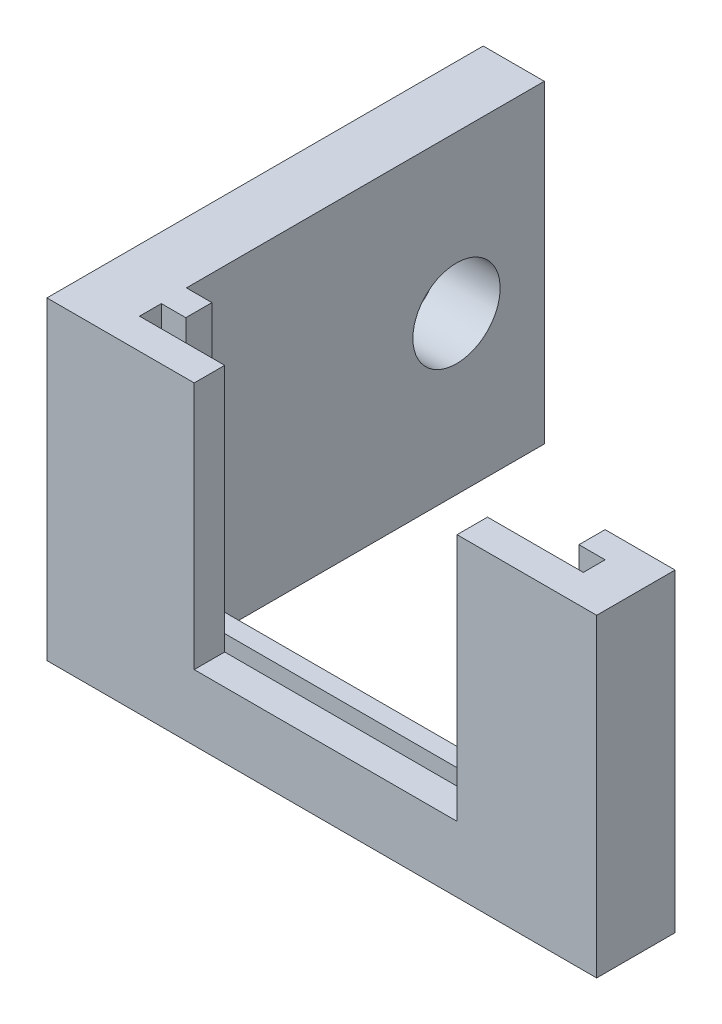
from build123d import *

# Parameters (mm, degrees)
SKETCH_2_W               = 3.5
SKETCH_2_H               = 18
EXTRUDE_1_DEPTH          = 25
SKETCH_3_W               = 4.492765479
SKETCH_3_H               = 18
EXTRUDE_2_DEPTH          = 28
CUT_EXTRUDE_1_DEPTH      = 15
SKETCH_5_W               = 18
SKETCH_5_H               = 1.12
CUT_EXTRUDE_2_DEPTH      = 4
SKETCH_6_W               = 15.061219586
SKETCH_6_H               = 9.659551438
CUT_EXTRUDE_3_DEPTH      = 26
SKETCH_7_R               = 2.5
CUT_EXTRUDE_4_DEPTH      = 1
CUT_EXTRUDE_4_DEPTH_BACK = 32.5
SKETCH_8_W               = 15.061219586
SKETCH_8_H               = 1.746167636
CUT_EXTRUDE_5_DEPTH      = 5.566914265


with BuildPart() as part:
    # Эскиз2 → Бобышка-Вытянуть1 (new body)
    with BuildSketch(Plane.XY):
        with Locations((1.75, 9)):
            Rectangle(SKETCH_2_W, SKETCH_2_H)
    extrude(amount=EXTRUDE_1_DEPTH)

    # Эскиз3 → Бобышка-Вытянуть2 (add)
    with BuildSketch(Plane(origin=(3.5, 0, 0), x_dir=(0, 0, -1), z_dir=(1, 0, 0))):
        with Locations((-22.753617261, 9)):
            Rectangle(SKETCH_3_W, SKETCH_3_H)
    extrude(amount=EXTRUDE_2_DEPTH)

    # Эскиз4 → Вырез-Вытянуть1 (cut)
    with BuildSketch(Plane(origin=(0, 18, 0), x_dir=(1, 0, 0), z_dir=(0, 1, 0))):
        Polygon((4.95959575, -20.507234521), (4.95959575, -22.003832364), (3.55959575, -22.003832364), (3.55959575, -23.253832364), (28.98959575, -23.253832364), (28.98959575, -22.003832364), (27.48959575, -22.003832364), (27.48959575, -20.507234521), align=None)
    extrude(amount=-CUT_EXTRUDE_1_DEPTH, mode=Mode.SUBTRACT)

    # Эскиз5 → Вырез-Вытянуть2 (cut, through all)
    with BuildSketch(Plane(origin=(0, 3, 0), x_dir=(1, 0, 0), z_dir=(0, 1, 0))):
        with Locations((15.035669989, -22.124024477)):
            Rectangle(SKETCH_5_W, SKETCH_5_H)
    extrude(amount=-CUT_EXTRUDE_2_DEPTH, mode=Mode.SUBTRACT)

    # Эскиз6 → Вырез-Вытянуть3 (cut, through all)
    with BuildSketch(Plane.XY.offset(25)):
        with Locations((15.969390207, 8.603310016)):
            Rectangle(SKETCH_6_W, SKETCH_6_H)
    extrude(amount=-CUT_EXTRUDE_3_DEPTH, mode=Mode.SUBTRACT)

    # Эскиз7 → Вырез-Вытянуть4 (cut, two sides)
    with BuildSketch(Plane.ZY) as cut_extrude_4_sk:
        with Locations((5.030711772, 9)):
            Circle(SKETCH_7_R)
    extrude(amount=CUT_EXTRUDE_4_DEPTH, mode=Mode.SUBTRACT)
    extrude(cut_extrude_4_sk.sketch, amount=-CUT_EXTRUDE_4_DEPTH_BACK, mode=Mode.SUBTRACT)

    # Эскиз8 → Вырез-Вытянуть5 (cut, through all)
    with BuildSketch(Plane.XZ.offset(-13.433085735)):
        with Locations((15.969390207, 24.126916182)):
            Rectangle(SKETCH_8_W, SKETCH_8_H)
    extrude(amount=-CUT_EXTRUDE_5_DEPTH, mode=Mode.SUBTRACT)


solid = part.part
